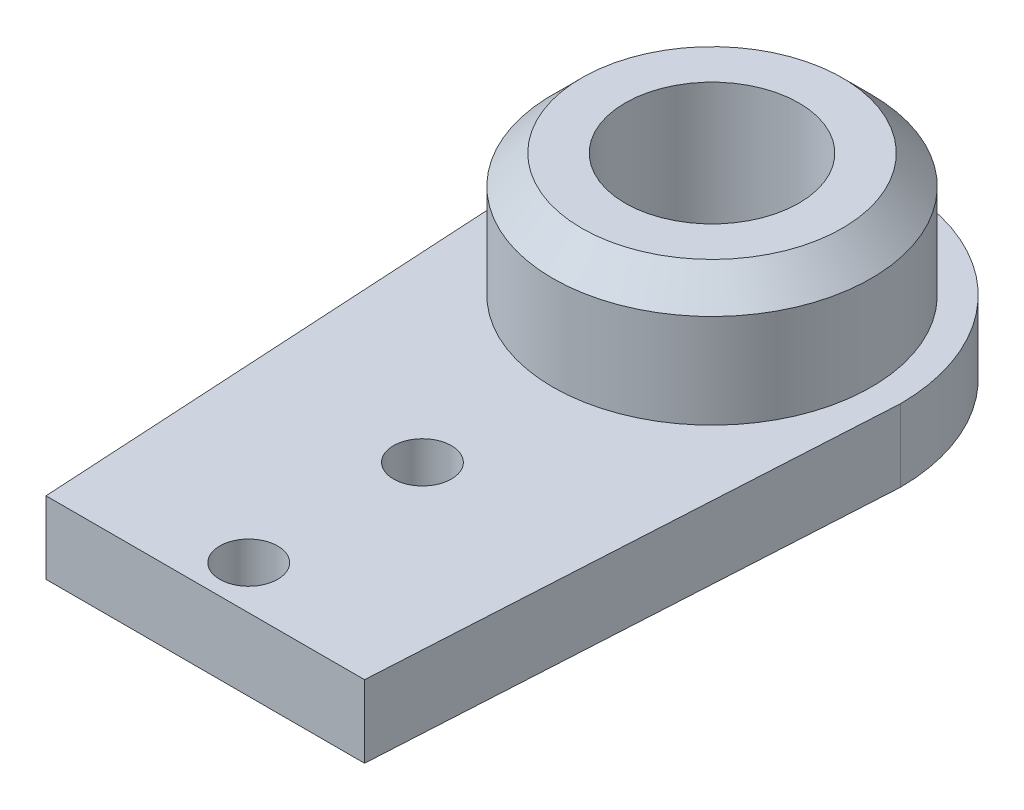
from build123d import *

# Parameters (mm, degrees)
SKETCH1_R           = 1
BOSS_EXTRUDE1_DEPTH = 2.5
SKETCH2_R           = 5.5
SKETCH2_R_2         = 3
BOSS_EXTRUDE3_DEPTH = 4.25
CUT_EXTRUDE1_REACH  = 4.5
SKETCH4_R           = 3
CHAMFER1_SIZE       = 1


with BuildPart() as part:
    # Sketch1 → Boss-Extrude1 (new body)
    with BuildSketch(Plane(origin=(0, 0, 0), x_dir=(1, 0, 0), z_dir=(0, 1, 0))):
        with BuildLine():
            ThreePointArc((6.5, 0), (0, 6.5), (-6.5, 0))
            Line((-6.5, 0), (-6.457689178, -0.740439382))
            Line((-6.457689178, -0.740439382), (-5.5, -17.5))
            Line((-5.5, -17.5), (5.5, -17.5))
            Line((5.5, -17.5), (6.457689178, -0.740439382))
            Line((6.457689178, -0.740439382), (6.5, 0))
        make_face()
        with Locations((0, -16)):
            Circle(SKETCH1_R, mode=Mode.SUBTRACT)
        with Locations((0, -10)):
            Circle(SKETCH1_R, mode=Mode.SUBTRACT)
    extrude(amount=BOSS_EXTRUDE1_DEPTH)

    # Sketch2 → Boss-Extrude3 (add)
    with BuildSketch(Plane(origin=(0, 2.5, 0), x_dir=(1, 0, 0), z_dir=(0, 1, 0))):
        Circle(SKETCH2_R)
        Circle(SKETCH2_R_2, mode=Mode.SUBTRACT)
    extrude(amount=BOSS_EXTRUDE3_DEPTH)

    # Sketch4 → Cut-Extrude1 (cut, up to next)
    with BuildSketch(Plane(origin=(0, 2.5, 0), x_dir=(1, 0, 0), z_dir=(0, 1, 0)), mode=Mode.PRIVATE) as cut_extrude1_sk1:
        Circle(SKETCH4_R)
    cut_extrude1_tool1 = extrude(cut_extrude1_sk1.sketch, amount=-CUT_EXTRUDE1_REACH, mode=Mode.PRIVATE) & part.part
    add(cut_extrude1_tool1.solids().sort_by_distance((0, 2.5, 0))[0], mode=Mode.SUBTRACT)

    # Chamfer1
    chamfer1_edges = [part.edges().sort_by_distance(p)[0] for p in [
        (-5.5, 6.75, 0),
    ]]
    chamfer(chamfer1_edges, length=CHAMFER1_SIZE)


solid = part.part
